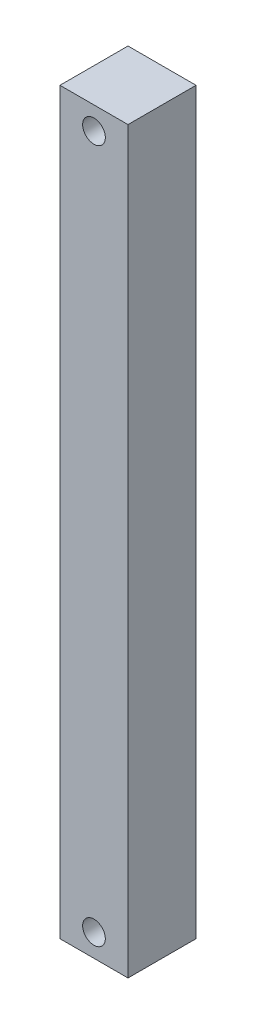
from build123d import *

# Parameters (mm, degrees)
SKETCH1_W           = 3
SKETCH1_H           = 3
BOSS_EXTRUDE1_DEPTH = 32.59
SKETCH2_R           = 0.5
CUT_EXTRUDE1_DEPTH  = 4
CUT_EXTRUDE2_REACH  = 5
SKETCH3_R           = 0.500716242


with BuildPart() as part:
    # Sketch1 → Boss-Extrude1 (new body)
    with BuildSketch(Plane(origin=(0, 0, 0), x_dir=(1, 0, 0), z_dir=(0, 1, 0))):
        Rectangle(SKETCH1_W, SKETCH1_H)
    extrude(amount=BOSS_EXTRUDE1_DEPTH)

    # Sketch2 → Cut-Extrude1 (cut, through all)
    with BuildSketch(Plane.XY.offset(1.5)):
        with Locations((0, 1)):
            Circle(SKETCH2_R)
    extrude(amount=-CUT_EXTRUDE1_DEPTH, mode=Mode.SUBTRACT)

    # Sketch3 → Cut-Extrude2 (cut, up to next)
    with BuildSketch(Plane.XY.offset(1.5), mode=Mode.PRIVATE) as cut_extrude2_sk1:
        with Locations((0, 31.59)):
            Circle(SKETCH3_R)
    cut_extrude2_tool1 = extrude(cut_extrude2_sk1.sketch, amount=-CUT_EXTRUDE2_REACH, mode=Mode.PRIVATE) & part.part
    add(cut_extrude2_tool1.solids().sort_by_distance((0, 31.59, 1.5))[0], mode=Mode.SUBTRACT)


solid = part.part
